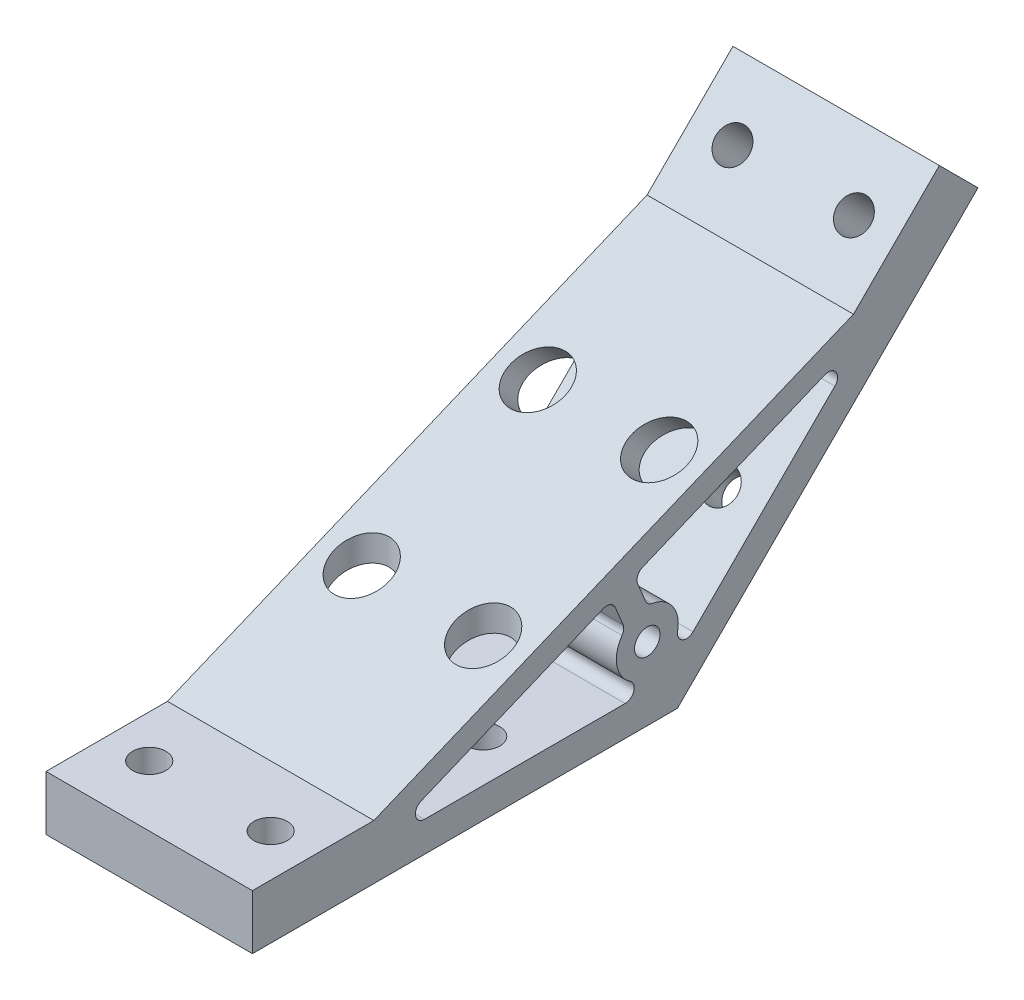
from build123d import *

# Parameters (mm, degrees)
BOSS_EXTRUDE1_DEPTH      = 17
BOSS_EXTRUDE1_DEPTH_BACK = 17
SKETCH1_R                = 2.1
SKETCH2_R                = 2.75
CUT_EXTRUDE1_DEPTH       = 9
SKETCH3_R                = 2.75
CUT_EXTRUDE2_DEPTH       = 9


with BuildPart() as part:
    # Sketch1 → Boss-Extrude1 (new, two sides: drawn at the far end of the back side and taken through both)
    with BuildSketch(Plane(origin=(0, 0, 0), x_dir=(0, 0, -1), z_dir=(1, 0, 0)).offset(-BOSS_EXTRUDE1_DEPTH_BACK)):
        Polygon((-70, 0), (0, 0), (49.497474683, 49.497474683), (43.133513652, 55.861435714), (28.991378029, 41.71930009), (-50, 9), (-70, 9), align=None)
        with Locations((-4.970562748, 12)):
            Circle(SKETCH1_R, mode=Mode.SUBTRACT)
        with BuildLine():
            Line((-6.551793043, 21.043679481), (-5.264121815, 17.934966139))
            ThreePointArc((-5.264121815, 17.934966139), (-4.812340099, 17.335290392), (-4.126543478, 17.029675086))
            ThreePointArc((-4.126543478, 17.029675086), (-0.768310337, 14.889822601), (0.028067769, 10.988222878))
            ThreePointArc((0.028067769, 10.988222878), (0.788934633, 9.368950353), (2.558913388, 9.6299812))
            Line((2.558913388, 9.6299812), (25.924897249, 32.995965061))
            ThreePointArc((25.924897249, 32.995965061), (26.111441495, 34.889980582), (24.290211928, 35.442444531))
            Line((24.290211928, 35.442444531), (-5.739998892, 23.003523928))
            ThreePointArc((-5.739998892, 23.003523928), (-6.551793043, 22.191729778), (-6.551793043, 21.043679481))
        make_face(mode=Mode.SUBTRACT)
        with BuildLine():
            Line((-41.663341292, 5), (-8.618850018, 5))
            ThreePointArc((-8.618850018, 5), (-7.182709356, 6.066987298), (-7.78969382, 7.75))
            ThreePointArc((-7.78969382, 7.75), (-9.985417083, 11.071971981), (-9.123891859, 14.959705611))
            ThreePointArc((-9.123891859, 14.959705611), (-8.855063072, 15.660739707), (-8.959639945, 16.40423241))
            Line((-8.959639945, 16.40423241), (-10.247311173, 19.512945751))
            ThreePointArc((-10.247311173, 19.512945751), (-11.059105323, 20.324739902), (-12.20715562, 20.324739902))
            Line((-12.20715562, 20.324739902), (-42.237366441, 7.885819299))
            ThreePointArc((-42.237366441, 7.885819299), (-43.134519213, 6.207364517), (-41.663341292, 5))
        make_face(mode=Mode.SUBTRACT)
    extrude(amount=BOSS_EXTRUDE1_DEPTH + BOSS_EXTRUDE1_DEPTH_BACK)

    # Sketch2 → Cut-Extrude1 (cut)
    with BuildSketch(Plane(origin=(0, 0, 0), x_dir=(-1, 0, 0), z_dir=(0, 1, 0))):
        with Locations((10, 60)):
            Circle(SKETCH2_R)
    extrude(amount=CUT_EXTRUDE1_DEPTH, mode=Mode.SUBTRACT)

    # Sketch3 → Cut-Extrude2 (cut)
    with BuildSketch(Plane(origin=(0, 0, 0), x_dir=(-1, 0, 0), z_dir=(0, 1, 0))):
        with Locations((-10, 60)):
            Circle(SKETCH3_R)
    extrude(amount=CUT_EXTRUDE2_DEPTH, mode=Mode.SUBTRACT)

    # Sketch4 → Cut-Revolve1 (revolve, cut)
    with BuildSketch(Plane(origin=(10, 0, 0), x_dir=(0, 0, -1), z_dir=(1, 0, 0))):
        Polygon((-25, 30), (-20.5, 30), (-20.5, 9), (-22.25, 9), (-22.25, 0), (-25, 0), align=None)
    revolve(axis=Axis((10, 0, 25), (0, 1, 0)), mode=Mode.SUBTRACT)

    # Sketch5 → Cut-Revolve2 (revolve, cut)
    with BuildSketch(Plane(origin=(10, 0, 0), x_dir=(0, 0, -1), z_dir=(1, 0, 0))):
        Polygon((17.67766953, 17.67766953), (15.733125881, 15.733125881), (9.369164851, 22.097086912), (8.131727984, 20.859650045), (-6.717514421, 35.70889245), (-3.535533906, 38.890872965), align=None)
    revolve(axis=Axis((10, 38.890872965, 3.535533906), (0, -0.7071067811865476, -0.7071067811865476)), mode=Mode.SUBTRACT)

    # Sketch6 → Cut-Revolve3 (revolve, cut)
    with BuildSketch(Plane(origin=(-10, 0, 0), x_dir=(0, 0, -1), z_dir=(1, 0, 0))):
        Polygon((-25, 30), (-20.5, 30), (-20.5, 9), (-22.25, 9), (-22.25, 0), (-25, 0), align=None)
    revolve(axis=Axis((-10, 0, 25), (0, 1, 0)), mode=Mode.SUBTRACT)

    # Sketch7 → Cut-Revolve4 (revolve, cut)
    with BuildSketch(Plane(origin=(-10, 0, 0), x_dir=(0, 0, -1), z_dir=(1, 0, 0))):
        Polygon((17.67766953, 17.67766953), (15.733125881, 15.733125881), (9.369164851, 22.097086912), (8.131727984, 20.859650045), (-6.717514421, 35.70889245), (-3.535533906, 38.890872965), align=None)
    revolve(axis=Axis((-10, 38.890872965, 3.535533906), (0, -0.7071067811865474, -0.7071067811865477)), mode=Mode.SUBTRACT)

    # Sketch8 → Cut-Revolve5 (revolve, cut)
    with BuildSketch(Plane(origin=(10, 0, 0), x_dir=(0, 0, -1), z_dir=(1, 0, 0))):
        Polygon((36.062445841, 48.790367902), (38.006989489, 50.73491155), (44.370950519, 44.370950519), (42.426406871, 42.426406871), align=None)
    revolve(axis=Axis((10, 42.426406871, -42.426406871), (0, 0.7071067811865476, 0.7071067811865476)), mode=Mode.SUBTRACT)

    # Sketch9 → Cut-Revolve6 (revolve, cut)
    with BuildSketch(Plane(origin=(-10, 0, 0), x_dir=(0, 0, -1), z_dir=(1, 0, 0))):
        Polygon((36.062445841, 48.790367902), (38.006989489, 50.73491155), (44.370950519, 44.370950519), (42.426406871, 42.426406871), align=None)
    revolve(axis=Axis((-10, 42.426406871, -42.426406871), (0, 0.7071067811865476, 0.7071067811865476)), mode=Mode.SUBTRACT)


solid = part.part
